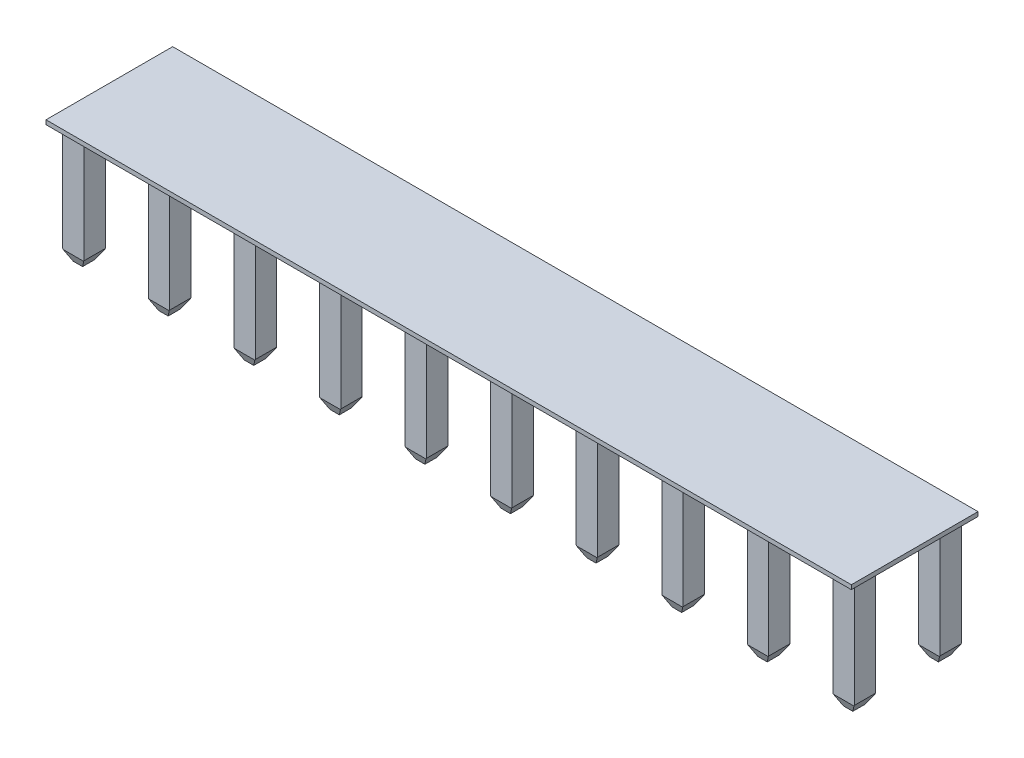
from build123d import *

# Parameters (mm, degrees)
SKETCH1_W            = 23.9014
SKETCH1_H            = 3.7592
BOSS_EXTRUDE1_DEPTH  = 0.127
SKETCH2_W            = 0.635
SKETCH2_H            = 0.635
BOSS_EXTRUDE2_DEPTH  = 3.5306
SKETCH3_W            = 0.635
SKETCH3_H            = 0.635
BOSS_EXTRUDE3_DEPTH  = 3.5306
SKETCH4_W            = 0.635
SKETCH4_H            = 0.635
BOSS_EXTRUDE4_DEPTH  = 3.5306
SKETCH5_W            = 0.635
SKETCH5_H            = 0.635
BOSS_EXTRUDE5_DEPTH  = 3.5306
SKETCH6_W            = 0.635
SKETCH6_H            = 0.635
BOSS_EXTRUDE6_DEPTH  = 3.5306
SKETCH7_W            = 0.635
SKETCH7_H            = 0.635
BOSS_EXTRUDE7_DEPTH  = 3.5306
SKETCH8_W            = 0.635
SKETCH8_H            = 0.635
BOSS_EXTRUDE8_DEPTH  = 3.5306
SKETCH9_W            = 0.635
SKETCH9_H            = 0.635
BOSS_EXTRUDE9_DEPTH  = 3.5306
SKETCH10_W           = 0.635
SKETCH10_H           = 0.635
BOSS_EXTRUDE10_DEPTH = 3.5306
SKETCH11_W           = 0.635
SKETCH11_H           = 0.635
BOSS_EXTRUDE11_DEPTH = 3.5306
SKETCH12_W           = 0.635
SKETCH12_H           = 0.635
BOSS_EXTRUDE12_DEPTH = 3.5306
SKETCH13_W           = 0.635
SKETCH13_H           = 0.635
BOSS_EXTRUDE13_DEPTH = 3.5306
SKETCH14_W           = 0.635
SKETCH14_H           = 0.635
BOSS_EXTRUDE14_DEPTH = 3.5306
SKETCH15_W           = 0.635
SKETCH15_H           = 0.635
BOSS_EXTRUDE15_DEPTH = 3.5306
SKETCH16_W           = 0.635
SKETCH16_H           = 0.635
BOSS_EXTRUDE16_DEPTH = 3.5306
SKETCH17_W           = 0.635
SKETCH17_H           = 0.635
BOSS_EXTRUDE17_DEPTH = 3.5306
SKETCH18_W           = 0.635
SKETCH18_H           = 0.635
BOSS_EXTRUDE18_DEPTH = 3.5306
SKETCH19_W           = 0.635
SKETCH19_H           = 0.635
BOSS_EXTRUDE19_DEPTH = 3.5306
SKETCH20_W           = 0.635
SKETCH20_H           = 0.635
BOSS_EXTRUDE20_DEPTH = 3.5306
SKETCH21_W           = 0.635
SKETCH21_H           = 0.635
BOSS_EXTRUDE21_DEPTH = 3.5306
CHAMFER1_SIZE        = 0.307958634
CHAMFER1_SIZE2       = 0.1778
CHAMFER2_SIZE        = 0.307958634
CHAMFER2_SIZE2       = 0.1778
CHAMFER3_SIZE        = 0.307958634
CHAMFER3_SIZE2       = 0.1778
CHAMFER4_SIZE        = 0.307958634
CHAMFER4_SIZE2       = 0.1778
CHAMFER5_SIZE        = 0.307958634
CHAMFER5_SIZE2       = 0.1778
CHAMFER6_SIZE        = 0.307958634
CHAMFER6_SIZE2       = 0.1778
CHAMFER7_SIZE        = 0.307958634
CHAMFER7_SIZE2       = 0.1778
CHAMFER8_SIZE        = 0.307958634
CHAMFER8_SIZE2       = 0.1778
CHAMFER9_SIZE        = 0.307958634
CHAMFER9_SIZE2       = 0.1778
CHAMFER10_SIZE       = 0.307958634
CHAMFER10_SIZE2      = 0.1778
CHAMFER11_SIZE       = 0.1778
CHAMFER11_SIZE2      = 0.307958634
CHAMFER12_SIZE       = 0.1778
CHAMFER12_SIZE2      = 0.307958634
CHAMFER13_SIZE       = 0.1778
CHAMFER13_SIZE2      = 0.307958634
CHAMFER14_SIZE       = 0.1778
CHAMFER14_SIZE2      = 0.307958634
CHAMFER15_SIZE       = 0.1778
CHAMFER15_SIZE2      = 0.307958634
CHAMFER16_SIZE       = 0.1778
CHAMFER16_SIZE2      = 0.307958634
CHAMFER17_SIZE       = 0.1778
CHAMFER17_SIZE2      = 0.307958634
CHAMFER18_SIZE       = 0.1778
CHAMFER18_SIZE2      = 0.307958634
CHAMFER19_SIZE       = 0.1778
CHAMFER19_SIZE2      = 0.307958634
CHAMFER20_SIZE       = 0.1778
CHAMFER20_SIZE2      = 0.307958634
CHAMFER21_SIZE       = 0.1778
CHAMFER21_SIZE2      = 0.307958634
CHAMFER22_SIZE       = 0.1778
CHAMFER22_SIZE2      = 0.307958634
CHAMFER23_SIZE       = 0.1778
CHAMFER23_SIZE2      = 0.307958634
CHAMFER24_SIZE       = 0.1778
CHAMFER24_SIZE2      = 0.307958634
CHAMFER25_SIZE       = 0.1778
CHAMFER25_SIZE2      = 0.307958634
CHAMFER26_SIZE       = 0.1778
CHAMFER26_SIZE2      = 0.307958634
CHAMFER27_SIZE       = 0.1778
CHAMFER27_SIZE2      = 0.307958634
CHAMFER28_SIZE       = 0.1778
CHAMFER28_SIZE2      = 0.307958634
CHAMFER29_SIZE       = 0.1778
CHAMFER29_SIZE2      = 0.307958634
CHAMFER30_SIZE       = 0.1778
CHAMFER30_SIZE2      = 0.307958634
CHAMFER31_SIZE       = 0.307958634
CHAMFER31_SIZE2      = 0.1778
CHAMFER32_SIZE       = 0.307958634
CHAMFER32_SIZE2      = 0.1778
CHAMFER33_SIZE       = 0.307958634
CHAMFER33_SIZE2      = 0.1778
CHAMFER34_SIZE       = 0.307958634
CHAMFER34_SIZE2      = 0.1778
CHAMFER35_SIZE       = 0.307958634
CHAMFER35_SIZE2      = 0.1778
CHAMFER36_SIZE       = 0.307958634
CHAMFER36_SIZE2      = 0.1778
CHAMFER37_SIZE       = 0.307958634
CHAMFER37_SIZE2      = 0.1778
CHAMFER38_SIZE       = 0.307958634
CHAMFER38_SIZE2      = 0.1778
CHAMFER39_SIZE       = 0.307958634
CHAMFER39_SIZE2      = 0.1778
CHAMFER40_SIZE       = 0.307958634
CHAMFER40_SIZE2      = 0.1778
CHAMFER41_SIZE       = 0.13335
CHAMFER41_SIZE2      = 0.285969998
CHAMFER42_SIZE       = 0.13335
CHAMFER42_SIZE2      = 0.285969998
CHAMFER43_SIZE       = 0.13335
CHAMFER43_SIZE2      = 0.285969998
CHAMFER44_SIZE       = 0.13335
CHAMFER44_SIZE2      = 0.285969998
CHAMFER45_SIZE       = 0.13335
CHAMFER45_SIZE2      = 0.285969998
CHAMFER46_SIZE       = 0.13335
CHAMFER46_SIZE2      = 0.285969998
CHAMFER47_SIZE       = 0.13335
CHAMFER47_SIZE2      = 0.285969998
CHAMFER48_SIZE       = 0.13335
CHAMFER48_SIZE2      = 0.285969998
CHAMFER49_SIZE       = 0.13335
CHAMFER49_SIZE2      = 0.285969998
CHAMFER50_SIZE       = 0.285969998
CHAMFER50_SIZE2      = 0.13335
CHAMFER51_SIZE       = 0.13335
CHAMFER51_SIZE2      = 0.285969998
CHAMFER52_SIZE       = 0.13335
CHAMFER52_SIZE2      = 0.285969998
CHAMFER53_SIZE       = 0.13335
CHAMFER53_SIZE2      = 0.285969998
CHAMFER54_SIZE       = 0.13335
CHAMFER54_SIZE2      = 0.285969998
CHAMFER55_SIZE       = 0.13335
CHAMFER55_SIZE2      = 0.285969998
CHAMFER56_SIZE       = 0.13335
CHAMFER56_SIZE2      = 0.285969998
CHAMFER57_SIZE       = 0.13335
CHAMFER57_SIZE2      = 0.285969998
CHAMFER58_SIZE       = 0.13335
CHAMFER58_SIZE2      = 0.285969998
CHAMFER59_SIZE       = 0.13335
CHAMFER59_SIZE2      = 0.285969998
CHAMFER60_SIZE       = 0.13335
CHAMFER60_SIZE2      = 0.285969998
CHAMFER61_SIZE       = 0.285969998
CHAMFER61_SIZE2      = 0.13335
CHAMFER62_SIZE       = 0.285969998
CHAMFER62_SIZE2      = 0.13335
CHAMFER63_SIZE       = 0.285969998
CHAMFER63_SIZE2      = 0.13335
CHAMFER64_SIZE       = 0.285969998
CHAMFER64_SIZE2      = 0.13335
CHAMFER65_SIZE       = 0.285969998
CHAMFER65_SIZE2      = 0.13335
CHAMFER66_SIZE       = 0.285969998
CHAMFER66_SIZE2      = 0.13335
CHAMFER67_SIZE       = 0.285969998
CHAMFER67_SIZE2      = 0.13335
CHAMFER68_SIZE       = 0.285969998
CHAMFER68_SIZE2      = 0.13335
CHAMFER69_SIZE       = 0.285969998
CHAMFER69_SIZE2      = 0.13335
CHAMFER70_SIZE       = 0.285969998
CHAMFER70_SIZE2      = 0.13335
CHAMFER71_SIZE       = 0.13335
CHAMFER71_SIZE2      = 0.285969998
CHAMFER72_SIZE       = 0.285969998
CHAMFER72_SIZE2      = 0.13335
CHAMFER73_SIZE       = 0.285969998
CHAMFER73_SIZE2      = 0.13335
CHAMFER74_SIZE       = 0.285969998
CHAMFER74_SIZE2      = 0.13335
CHAMFER75_SIZE       = 0.285969998
CHAMFER75_SIZE2      = 0.13335
CHAMFER76_SIZE       = 0.285969998
CHAMFER76_SIZE2      = 0.13335
CHAMFER77_SIZE       = 0.285969998
CHAMFER77_SIZE2      = 0.13335
CHAMFER78_SIZE       = 0.285969998
CHAMFER78_SIZE2      = 0.13335
CHAMFER79_SIZE       = 0.285969998
CHAMFER79_SIZE2      = 0.13335
CHAMFER80_SIZE       = 0.285969998
CHAMFER80_SIZE2      = 0.13335


with BuildPart() as part:
    # Sketch1 → Boss-Extrude1 (new body)
    with BuildSketch(Plane.XZ.offset(-3.5306)):
        Rectangle(SKETCH1_W, SKETCH1_H)
    extrude(amount=-BOSS_EXTRUDE1_DEPTH)

    # Sketch2 → Boss-Extrude2 (add)
    with BuildSketch(Plane.XZ.offset(-3.5306)):
        with Locations((11.43, 1.27)):
            Rectangle(SKETCH2_W, SKETCH2_H)
    extrude(amount=BOSS_EXTRUDE2_DEPTH)

    # Sketch3 → Boss-Extrude3 (add)
    with BuildSketch(Plane.XZ.offset(-3.5306)):
        with Locations((8.89, 1.27)):
            Rectangle(SKETCH3_W, SKETCH3_H)
    extrude(amount=BOSS_EXTRUDE3_DEPTH)

    # Sketch4 → Boss-Extrude4 (add)
    with BuildSketch(Plane.XZ.offset(-3.5306)):
        with Locations((6.35, 1.27)):
            Rectangle(SKETCH4_W, SKETCH4_H)
    extrude(amount=BOSS_EXTRUDE4_DEPTH)

    # Sketch5 → Boss-Extrude5 (add)
    with BuildSketch(Plane.XZ.offset(-3.5306)):
        with Locations((3.81, 1.27)):
            Rectangle(SKETCH5_W, SKETCH5_H)
    extrude(amount=BOSS_EXTRUDE5_DEPTH)

    # Sketch6 → Boss-Extrude6 (add)
    with BuildSketch(Plane.XZ.offset(-3.5306)):
        with Locations((1.27, 1.27)):
            Rectangle(SKETCH6_W, SKETCH6_H)
    extrude(amount=BOSS_EXTRUDE6_DEPTH)

    # Sketch7 → Boss-Extrude7 (add)
    with BuildSketch(Plane.XZ.offset(-3.5306)):
        with Locations((-1.27, 1.27)):
            Rectangle(SKETCH7_W, SKETCH7_H)
    extrude(amount=BOSS_EXTRUDE7_DEPTH)

    # Sketch8 → Boss-Extrude8 (add)
    with BuildSketch(Plane.XZ.offset(-3.5306)):
        with Locations((-3.81, 1.27)):
            Rectangle(SKETCH8_W, SKETCH8_H)
    extrude(amount=BOSS_EXTRUDE8_DEPTH)

    # Sketch9 → Boss-Extrude9 (add)
    with BuildSketch(Plane.XZ.offset(-3.5306)):
        with Locations((-6.35, 1.27)):
            Rectangle(SKETCH9_W, SKETCH9_H)
    extrude(amount=BOSS_EXTRUDE9_DEPTH)

    # Sketch10 → Boss-Extrude10 (add)
    with BuildSketch(Plane.XZ.offset(-3.5306)):
        with Locations((-8.89, 1.27)):
            Rectangle(SKETCH10_W, SKETCH10_H)
    extrude(amount=BOSS_EXTRUDE10_DEPTH)

    # Sketch11 → Boss-Extrude11 (add)
    with BuildSketch(Plane.XZ.offset(-3.5306)):
        with Locations((-11.43, 1.27)):
            Rectangle(SKETCH11_W, SKETCH11_H)
    extrude(amount=BOSS_EXTRUDE11_DEPTH)

    # Sketch12 → Boss-Extrude12 (add)
    with BuildSketch(Plane.XZ.offset(-3.5306)):
        with Locations((11.43, -1.27)):
            Rectangle(SKETCH12_W, SKETCH12_H)
    extrude(amount=BOSS_EXTRUDE12_DEPTH)

    # Sketch13 → Boss-Extrude13 (add)
    with BuildSketch(Plane.XZ.offset(-3.5306)):
        with Locations((8.89, -1.27)):
            Rectangle(SKETCH13_W, SKETCH13_H)
    extrude(amount=BOSS_EXTRUDE13_DEPTH)

    # Sketch14 → Boss-Extrude14 (add)
    with BuildSketch(Plane.XZ.offset(-3.5306)):
        with Locations((6.35, -1.27)):
            Rectangle(SKETCH14_W, SKETCH14_H)
    extrude(amount=BOSS_EXTRUDE14_DEPTH)

    # Sketch15 → Boss-Extrude15 (add)
    with BuildSketch(Plane.XZ.offset(-3.5306)):
        with Locations((3.81, -1.27)):
            Rectangle(SKETCH15_W, SKETCH15_H)
    extrude(amount=BOSS_EXTRUDE15_DEPTH)

    # Sketch16 → Boss-Extrude16 (add)
    with BuildSketch(Plane.XZ.offset(-3.5306)):
        with Locations((1.27, -1.27)):
            Rectangle(SKETCH16_W, SKETCH16_H)
    extrude(amount=BOSS_EXTRUDE16_DEPTH)

    # Sketch17 → Boss-Extrude17 (add)
    with BuildSketch(Plane.XZ.offset(-3.5306)):
        with Locations((-1.27, -1.27)):
            Rectangle(SKETCH17_W, SKETCH17_H)
    extrude(amount=BOSS_EXTRUDE17_DEPTH)

    # Sketch18 → Boss-Extrude18 (add)
    with BuildSketch(Plane.XZ.offset(-3.5306)):
        with Locations((-3.81, -1.27)):
            Rectangle(SKETCH18_W, SKETCH18_H)
    extrude(amount=BOSS_EXTRUDE18_DEPTH)

    # Sketch19 → Boss-Extrude19 (add)
    with BuildSketch(Plane.XZ.offset(-3.5306)):
        with Locations((-6.35, -1.27)):
            Rectangle(SKETCH19_W, SKETCH19_H)
    extrude(amount=BOSS_EXTRUDE19_DEPTH)

    # Sketch20 → Boss-Extrude20 (add)
    with BuildSketch(Plane.XZ.offset(-3.5306)):
        with Locations((-8.89, -1.27)):
            Rectangle(SKETCH20_W, SKETCH20_H)
    extrude(amount=BOSS_EXTRUDE20_DEPTH)

    # Sketch21 → Boss-Extrude21 (add)
    with BuildSketch(Plane.XZ.offset(-3.5306)):
        with Locations((-11.43, -1.27)):
            Rectangle(SKETCH21_W, SKETCH21_H)
    extrude(amount=BOSS_EXTRUDE21_DEPTH)

    # Chamfer1
    chamfer1_edges = [part.edges().sort_by_distance(p)[0] for p in [
        (11.7475, 0, 1.27),
    ]]
    chamfer1_side = [part.faces().sort_by_distance(p)[0] for p in [
        (11.7475, 1.7653, 1.27),
    ]]
    chamfer(chamfer1_edges, length=CHAMFER1_SIZE, length2=CHAMFER1_SIZE2, reference=chamfer1_side[0])

    # Chamfer2
    chamfer2_edges = [part.edges().sort_by_distance(p)[0] for p in [
        (9.2075, 0, 1.27),
    ]]
    chamfer2_side = [part.faces().sort_by_distance(p)[0] for p in [
        (9.2075, 1.7653, 1.27),
    ]]
    chamfer(chamfer2_edges, length=CHAMFER2_SIZE, length2=CHAMFER2_SIZE2, reference=chamfer2_side[0])

    # Chamfer3
    chamfer3_edges = [part.edges().sort_by_distance(p)[0] for p in [
        (6.6675, 0, 1.27),
    ]]
    chamfer3_side = [part.faces().sort_by_distance(p)[0] for p in [
        (6.6675, 1.7653, 1.27),
    ]]
    chamfer(chamfer3_edges, length=CHAMFER3_SIZE, length2=CHAMFER3_SIZE2, reference=chamfer3_side[0])

    # Chamfer4
    chamfer4_edges = [part.edges().sort_by_distance(p)[0] for p in [
        (4.1275, 0, 1.27),
    ]]
    chamfer4_side = [part.faces().sort_by_distance(p)[0] for p in [
        (4.1275, 1.7653, 1.27),
    ]]
    chamfer(chamfer4_edges, length=CHAMFER4_SIZE, length2=CHAMFER4_SIZE2, reference=chamfer4_side[0])

    # Chamfer5
    chamfer5_edges = [part.edges().sort_by_distance(p)[0] for p in [
        (1.5875, 0, 1.27),
    ]]
    chamfer5_side = [part.faces().sort_by_distance(p)[0] for p in [
        (1.5875, 1.7653, 1.27),
    ]]
    chamfer(chamfer5_edges, length=CHAMFER5_SIZE, length2=CHAMFER5_SIZE2, reference=chamfer5_side[0])

    # Chamfer6
    chamfer6_edges = [part.edges().sort_by_distance(p)[0] for p in [
        (-0.9525, 0, 1.27),
    ]]
    chamfer6_side = [part.faces().sort_by_distance(p)[0] for p in [
        (-0.9525, 1.7653, 1.27),
    ]]
    chamfer(chamfer6_edges, length=CHAMFER6_SIZE, length2=CHAMFER6_SIZE2, reference=chamfer6_side[0])

    # Chamfer7
    chamfer7_edges = [part.edges().sort_by_distance(p)[0] for p in [
        (-3.4925, 0, 1.27),
    ]]
    chamfer7_side = [part.faces().sort_by_distance(p)[0] for p in [
        (-3.4925, 1.7653, 1.27),
    ]]
    chamfer(chamfer7_edges, length=CHAMFER7_SIZE, length2=CHAMFER7_SIZE2, reference=chamfer7_side[0])

    # Chamfer8
    chamfer8_edges = [part.edges().sort_by_distance(p)[0] for p in [
        (-6.0325, 0, 1.27),
    ]]
    chamfer8_side = [part.faces().sort_by_distance(p)[0] for p in [
        (-6.0325, 1.7653, 1.27),
    ]]
    chamfer(chamfer8_edges, length=CHAMFER8_SIZE, length2=CHAMFER8_SIZE2, reference=chamfer8_side[0])

    # Chamfer9
    chamfer9_edges = [part.edges().sort_by_distance(p)[0] for p in [
        (-8.5725, 0, 1.27),
    ]]
    chamfer9_side = [part.faces().sort_by_distance(p)[0] for p in [
        (-8.5725, 1.7653, 1.27),
    ]]
    chamfer(chamfer9_edges, length=CHAMFER9_SIZE, length2=CHAMFER9_SIZE2, reference=chamfer9_side[0])

    # Chamfer10
    chamfer10_edges = [part.edges().sort_by_distance(p)[0] for p in [
        (-11.1125, 0, 1.27),
    ]]
    chamfer10_side = [part.faces().sort_by_distance(p)[0] for p in [
        (-11.1125, 1.7653, 1.27),
    ]]
    chamfer(chamfer10_edges, length=CHAMFER10_SIZE, length2=CHAMFER10_SIZE2, reference=chamfer10_side[0])

    # Chamfer11
    chamfer11_edges = [part.edges().sort_by_distance(p)[0] for p in [
        (11.1125, 0, 1.27),
    ]]
    chamfer11_side = [part.faces().sort_by_distance(p)[0] for p in [
        (11.3411, 0, 1.27),
    ]]
    chamfer(chamfer11_edges, length=CHAMFER11_SIZE, length2=CHAMFER11_SIZE2, reference=chamfer11_side[0])

    # Chamfer12
    chamfer12_edges = [part.edges().sort_by_distance(p)[0] for p in [
        (8.5725, 0, 1.27),
    ]]
    chamfer12_side = [part.faces().sort_by_distance(p)[0] for p in [
        (8.8011, 0, 1.27),
    ]]
    chamfer(chamfer12_edges, length=CHAMFER12_SIZE, length2=CHAMFER12_SIZE2, reference=chamfer12_side[0])

    # Chamfer13
    chamfer13_edges = [part.edges().sort_by_distance(p)[0] for p in [
        (6.0325, 0, 1.27),
    ]]
    chamfer13_side = [part.faces().sort_by_distance(p)[0] for p in [
        (6.2611, 0, 1.27),
    ]]
    chamfer(chamfer13_edges, length=CHAMFER13_SIZE, length2=CHAMFER13_SIZE2, reference=chamfer13_side[0])

    # Chamfer14
    chamfer14_edges = [part.edges().sort_by_distance(p)[0] for p in [
        (3.4925, 0, 1.27),
    ]]
    chamfer14_side = [part.faces().sort_by_distance(p)[0] for p in [
        (3.7211, 0, 1.27),
    ]]
    chamfer(chamfer14_edges, length=CHAMFER14_SIZE, length2=CHAMFER14_SIZE2, reference=chamfer14_side[0])

    # Chamfer15
    chamfer15_edges = [part.edges().sort_by_distance(p)[0] for p in [
        (0.9525, 0, 1.27),
    ]]
    chamfer15_side = [part.faces().sort_by_distance(p)[0] for p in [
        (1.1811, 0, 1.27),
    ]]
    chamfer(chamfer15_edges, length=CHAMFER15_SIZE, length2=CHAMFER15_SIZE2, reference=chamfer15_side[0])

    # Chamfer16
    chamfer16_edges = [part.edges().sort_by_distance(p)[0] for p in [
        (-1.5875, 0, 1.27),
    ]]
    chamfer16_side = [part.faces().sort_by_distance(p)[0] for p in [
        (-1.3589, 0, 1.27),
    ]]
    chamfer(chamfer16_edges, length=CHAMFER16_SIZE, length2=CHAMFER16_SIZE2, reference=chamfer16_side[0])

    # Chamfer17
    chamfer17_edges = [part.edges().sort_by_distance(p)[0] for p in [
        (-4.1275, 0, 1.27),
    ]]
    chamfer17_side = [part.faces().sort_by_distance(p)[0] for p in [
        (-3.8989, 0, 1.27),
    ]]
    chamfer(chamfer17_edges, length=CHAMFER17_SIZE, length2=CHAMFER17_SIZE2, reference=chamfer17_side[0])

    # Chamfer18
    chamfer18_edges = [part.edges().sort_by_distance(p)[0] for p in [
        (-6.6675, 0, 1.27),
    ]]
    chamfer18_side = [part.faces().sort_by_distance(p)[0] for p in [
        (-6.4389, 0, 1.27),
    ]]
    chamfer(chamfer18_edges, length=CHAMFER18_SIZE, length2=CHAMFER18_SIZE2, reference=chamfer18_side[0])

    # Chamfer19
    chamfer19_edges = [part.edges().sort_by_distance(p)[0] for p in [
        (-9.2075, 0, 1.27),
    ]]
    chamfer19_side = [part.faces().sort_by_distance(p)[0] for p in [
        (-8.9789, 0, 1.27),
    ]]
    chamfer(chamfer19_edges, length=CHAMFER19_SIZE, length2=CHAMFER19_SIZE2, reference=chamfer19_side[0])

    # Chamfer20
    chamfer20_edges = [part.edges().sort_by_distance(p)[0] for p in [
        (-11.7475, 0, 1.27),
    ]]
    chamfer20_side = [part.faces().sort_by_distance(p)[0] for p in [
        (-11.5189, 0, 1.27),
    ]]
    chamfer(chamfer20_edges, length=CHAMFER20_SIZE, length2=CHAMFER20_SIZE2, reference=chamfer20_side[0])

    # Chamfer21
    chamfer21_edges = [part.edges().sort_by_distance(p)[0] for p in [
        (11.7475, 0, -1.27),
    ]]
    chamfer21_side = [part.faces().sort_by_distance(p)[0] for p in [
        (11.43, 0, -1.27),
    ]]
    chamfer(chamfer21_edges, length=CHAMFER21_SIZE, length2=CHAMFER21_SIZE2, reference=chamfer21_side[0])

    # Chamfer22
    chamfer22_edges = [part.edges().sort_by_distance(p)[0] for p in [
        (9.2075, 0, -1.27),
    ]]
    chamfer22_side = [part.faces().sort_by_distance(p)[0] for p in [
        (8.89, 0, -1.27),
    ]]
    chamfer(chamfer22_edges, length=CHAMFER22_SIZE, length2=CHAMFER22_SIZE2, reference=chamfer22_side[0])

    # Chamfer23
    chamfer23_edges = [part.edges().sort_by_distance(p)[0] for p in [
        (6.6675, 0, -1.27),
    ]]
    chamfer23_side = [part.faces().sort_by_distance(p)[0] for p in [
        (6.35, 0, -1.27),
    ]]
    chamfer(chamfer23_edges, length=CHAMFER23_SIZE, length2=CHAMFER23_SIZE2, reference=chamfer23_side[0])

    # Chamfer24
    chamfer24_edges = [part.edges().sort_by_distance(p)[0] for p in [
        (4.1275, 0, -1.27),
    ]]
    chamfer24_side = [part.faces().sort_by_distance(p)[0] for p in [
        (3.81, 0, -1.27),
    ]]
    chamfer(chamfer24_edges, length=CHAMFER24_SIZE, length2=CHAMFER24_SIZE2, reference=chamfer24_side[0])

    # Chamfer25
    chamfer25_edges = [part.edges().sort_by_distance(p)[0] for p in [
        (1.5875, 0, -1.27),
    ]]
    chamfer25_side = [part.faces().sort_by_distance(p)[0] for p in [
        (1.27, 0, -1.27),
    ]]
    chamfer(chamfer25_edges, length=CHAMFER25_SIZE, length2=CHAMFER25_SIZE2, reference=chamfer25_side[0])

    # Chamfer26
    chamfer26_edges = [part.edges().sort_by_distance(p)[0] for p in [
        (-0.9525, 0, -1.27),
    ]]
    chamfer26_side = [part.faces().sort_by_distance(p)[0] for p in [
        (-1.27, 0, -1.27),
    ]]
    chamfer(chamfer26_edges, length=CHAMFER26_SIZE, length2=CHAMFER26_SIZE2, reference=chamfer26_side[0])

    # Chamfer27
    chamfer27_edges = [part.edges().sort_by_distance(p)[0] for p in [
        (-3.4925, 0, -1.27),
    ]]
    chamfer27_side = [part.faces().sort_by_distance(p)[0] for p in [
        (-3.81, 0, -1.27),
    ]]
    chamfer(chamfer27_edges, length=CHAMFER27_SIZE, length2=CHAMFER27_SIZE2, reference=chamfer27_side[0])

    # Chamfer28
    chamfer28_edges = [part.edges().sort_by_distance(p)[0] for p in [
        (-6.0325, 0, -1.27),
    ]]
    chamfer28_side = [part.faces().sort_by_distance(p)[0] for p in [
        (-6.35, 0, -1.27),
    ]]
    chamfer(chamfer28_edges, length=CHAMFER28_SIZE, length2=CHAMFER28_SIZE2, reference=chamfer28_side[0])

    # Chamfer29
    chamfer29_edges = [part.edges().sort_by_distance(p)[0] for p in [
        (-8.5725, 0, -1.27),
    ]]
    chamfer29_side = [part.faces().sort_by_distance(p)[0] for p in [
        (-8.89, 0, -1.27),
    ]]
    chamfer(chamfer29_edges, length=CHAMFER29_SIZE, length2=CHAMFER29_SIZE2, reference=chamfer29_side[0])

    # Chamfer30
    chamfer30_edges = [part.edges().sort_by_distance(p)[0] for p in [
        (-11.1125, 0, -1.27),
    ]]
    chamfer30_side = [part.faces().sort_by_distance(p)[0] for p in [
        (-11.43, 0, -1.27),
    ]]
    chamfer(chamfer30_edges, length=CHAMFER30_SIZE, length2=CHAMFER30_SIZE2, reference=chamfer30_side[0])

    # Chamfer31
    chamfer31_edges = [part.edges().sort_by_distance(p)[0] for p in [
        (11.1125, 0, -1.27),
    ]]
    chamfer31_side = [part.faces().sort_by_distance(p)[0] for p in [
        (11.1125, 1.7653, -1.27),
    ]]
    chamfer(chamfer31_edges, length=CHAMFER31_SIZE, length2=CHAMFER31_SIZE2, reference=chamfer31_side[0])

    # Chamfer32
    chamfer32_edges = [part.edges().sort_by_distance(p)[0] for p in [
        (8.5725, 0, -1.27),
    ]]
    chamfer32_side = [part.faces().sort_by_distance(p)[0] for p in [
        (8.5725, 1.7653, -1.27),
    ]]
    chamfer(chamfer32_edges, length=CHAMFER32_SIZE, length2=CHAMFER32_SIZE2, reference=chamfer32_side[0])

    # Chamfer33
    chamfer33_edges = [part.edges().sort_by_distance(p)[0] for p in [
        (6.0325, 0, -1.27),
    ]]
    chamfer33_side = [part.faces().sort_by_distance(p)[0] for p in [
        (6.0325, 1.7653, -1.27),
    ]]
    chamfer(chamfer33_edges, length=CHAMFER33_SIZE, length2=CHAMFER33_SIZE2, reference=chamfer33_side[0])

    # Chamfer34
    chamfer34_edges = [part.edges().sort_by_distance(p)[0] for p in [
        (3.4925, 0, -1.27),
    ]]
    chamfer34_side = [part.faces().sort_by_distance(p)[0] for p in [
        (3.4925, 1.7653, -1.27),
    ]]
    chamfer(chamfer34_edges, length=CHAMFER34_SIZE, length2=CHAMFER34_SIZE2, reference=chamfer34_side[0])

    # Chamfer35
    chamfer35_edges = [part.edges().sort_by_distance(p)[0] for p in [
        (0.9525, 0, -1.27),
    ]]
    chamfer35_side = [part.faces().sort_by_distance(p)[0] for p in [
        (0.9525, 1.7653, -1.27),
    ]]
    chamfer(chamfer35_edges, length=CHAMFER35_SIZE, length2=CHAMFER35_SIZE2, reference=chamfer35_side[0])

    # Chamfer36
    chamfer36_edges = [part.edges().sort_by_distance(p)[0] for p in [
        (-1.5875, 0, -1.27),
    ]]
    chamfer36_side = [part.faces().sort_by_distance(p)[0] for p in [
        (-1.5875, 1.7653, -1.27),
    ]]
    chamfer(chamfer36_edges, length=CHAMFER36_SIZE, length2=CHAMFER36_SIZE2, reference=chamfer36_side[0])

    # Chamfer37
    chamfer37_edges = [part.edges().sort_by_distance(p)[0] for p in [
        (-4.1275, 0, -1.27),
    ]]
    chamfer37_side = [part.faces().sort_by_distance(p)[0] for p in [
        (-4.1275, 1.7653, -1.27),
    ]]
    chamfer(chamfer37_edges, length=CHAMFER37_SIZE, length2=CHAMFER37_SIZE2, reference=chamfer37_side[0])

    # Chamfer38
    chamfer38_edges = [part.edges().sort_by_distance(p)[0] for p in [
        (-6.6675, 0, -1.27),
    ]]
    chamfer38_side = [part.faces().sort_by_distance(p)[0] for p in [
        (-6.6675, 1.7653, -1.27),
    ]]
    chamfer(chamfer38_edges, length=CHAMFER38_SIZE, length2=CHAMFER38_SIZE2, reference=chamfer38_side[0])

    # Chamfer39
    chamfer39_edges = [part.edges().sort_by_distance(p)[0] for p in [
        (-9.2075, 0, -1.27),
    ]]
    chamfer39_side = [part.faces().sort_by_distance(p)[0] for p in [
        (-9.2075, 1.7653, -1.27),
    ]]
    chamfer(chamfer39_edges, length=CHAMFER39_SIZE, length2=CHAMFER39_SIZE2, reference=chamfer39_side[0])

    # Chamfer40
    chamfer40_edges = [part.edges().sort_by_distance(p)[0] for p in [
        (-11.7475, 0, -1.27),
    ]]
    chamfer40_side = [part.faces().sort_by_distance(p)[0] for p in [
        (-11.7475, 1.7653, -1.27),
    ]]
    chamfer(chamfer40_edges, length=CHAMFER40_SIZE, length2=CHAMFER40_SIZE2, reference=chamfer40_side[0])

    # Chamfer41
    chamfer41_edges = [part.edges().sort_by_distance(p)[0] for p in [
        (11.43, 0, -0.9525),
    ]]
    chamfer41_side = [part.faces().sort_by_distance(p)[0] for p in [
        (11.43, 0, -1.27),
    ]]
    chamfer(chamfer41_edges, length=CHAMFER41_SIZE, length2=CHAMFER41_SIZE2, reference=chamfer41_side[0])

    # Chamfer42
    chamfer42_edges = [part.edges().sort_by_distance(p)[0] for p in [
        (8.89, 0, -0.9525),
    ]]
    chamfer42_side = [part.faces().sort_by_distance(p)[0] for p in [
        (8.89, 0, -1.27),
    ]]
    chamfer(chamfer42_edges, length=CHAMFER42_SIZE, length2=CHAMFER42_SIZE2, reference=chamfer42_side[0])

    # Chamfer43
    chamfer43_edges = [part.edges().sort_by_distance(p)[0] for p in [
        (6.35, 0, -0.9525),
    ]]
    chamfer43_side = [part.faces().sort_by_distance(p)[0] for p in [
        (6.35, 0, -1.27),
    ]]
    chamfer(chamfer43_edges, length=CHAMFER43_SIZE, length2=CHAMFER43_SIZE2, reference=chamfer43_side[0])

    # Chamfer44
    chamfer44_edges = [part.edges().sort_by_distance(p)[0] for p in [
        (3.81, 0, -0.9525),
    ]]
    chamfer44_side = [part.faces().sort_by_distance(p)[0] for p in [
        (3.81, 0, -1.27),
    ]]
    chamfer(chamfer44_edges, length=CHAMFER44_SIZE, length2=CHAMFER44_SIZE2, reference=chamfer44_side[0])

    # Chamfer45
    chamfer45_edges = [part.edges().sort_by_distance(p)[0] for p in [
        (1.27, 0, -0.9525),
    ]]
    chamfer45_side = [part.faces().sort_by_distance(p)[0] for p in [
        (1.27, 0, -1.27),
    ]]
    chamfer(chamfer45_edges, length=CHAMFER45_SIZE, length2=CHAMFER45_SIZE2, reference=chamfer45_side[0])

    # Chamfer46
    chamfer46_edges = [part.edges().sort_by_distance(p)[0] for p in [
        (-1.27, 0, -0.9525),
    ]]
    chamfer46_side = [part.faces().sort_by_distance(p)[0] for p in [
        (-1.27, 0, -1.27),
    ]]
    chamfer(chamfer46_edges, length=CHAMFER46_SIZE, length2=CHAMFER46_SIZE2, reference=chamfer46_side[0])

    # Chamfer47
    chamfer47_edges = [part.edges().sort_by_distance(p)[0] for p in [
        (-3.81, 0, -0.9525),
    ]]
    chamfer47_side = [part.faces().sort_by_distance(p)[0] for p in [
        (-3.81, 0, -1.27),
    ]]
    chamfer(chamfer47_edges, length=CHAMFER47_SIZE, length2=CHAMFER47_SIZE2, reference=chamfer47_side[0])

    # Chamfer48
    chamfer48_edges = [part.edges().sort_by_distance(p)[0] for p in [
        (-6.35, 0, -0.9525),
    ]]
    chamfer48_side = [part.faces().sort_by_distance(p)[0] for p in [
        (-6.35, 0, -1.27),
    ]]
    chamfer(chamfer48_edges, length=CHAMFER48_SIZE, length2=CHAMFER48_SIZE2, reference=chamfer48_side[0])

    # Chamfer49
    chamfer49_edges = [part.edges().sort_by_distance(p)[0] for p in [
        (-8.89, 0, -0.9525),
    ]]
    chamfer49_side = [part.faces().sort_by_distance(p)[0] for p in [
        (-8.89, 0, -1.27),
    ]]
    chamfer(chamfer49_edges, length=CHAMFER49_SIZE, length2=CHAMFER49_SIZE2, reference=chamfer49_side[0])

    # Chamfer50
    chamfer50_edges = [part.edges().sort_by_distance(p)[0] for p in [
        (-11.43, 0, -0.9525),
    ]]
    chamfer50_side = [part.faces().sort_by_distance(p)[0] for p in [
        (-11.43, 1.806923683, -0.9525),
    ]]
    chamfer(chamfer50_edges, length=CHAMFER50_SIZE, length2=CHAMFER50_SIZE2, reference=chamfer50_side[0])

    # Chamfer51
    chamfer51_edges = [part.edges().sort_by_distance(p)[0] for p in [
        (-11.43, 0, -1.5875),
    ]]
    chamfer51_side = [part.faces().sort_by_distance(p)[0] for p in [
        (-11.43, 0, -1.336675),
    ]]
    chamfer(chamfer51_edges, length=CHAMFER51_SIZE, length2=CHAMFER51_SIZE2, reference=chamfer51_side[0])

    # Chamfer52
    chamfer52_edges = [part.edges().sort_by_distance(p)[0] for p in [
        (11.43, 0, 1.5875),
    ]]
    chamfer52_side = [part.faces().sort_by_distance(p)[0] for p in [
        (11.43, 0, 1.27),
    ]]
    chamfer(chamfer52_edges, length=CHAMFER52_SIZE, length2=CHAMFER52_SIZE2, reference=chamfer52_side[0])

    # Chamfer53
    chamfer53_edges = [part.edges().sort_by_distance(p)[0] for p in [
        (8.89, 0, 1.5875),
    ]]
    chamfer53_side = [part.faces().sort_by_distance(p)[0] for p in [
        (8.89, 0, 1.27),
    ]]
    chamfer(chamfer53_edges, length=CHAMFER53_SIZE, length2=CHAMFER53_SIZE2, reference=chamfer53_side[0])

    # Chamfer54
    chamfer54_edges = [part.edges().sort_by_distance(p)[0] for p in [
        (6.35, 0, 1.5875),
    ]]
    chamfer54_side = [part.faces().sort_by_distance(p)[0] for p in [
        (6.35, 0, 1.27),
    ]]
    chamfer(chamfer54_edges, length=CHAMFER54_SIZE, length2=CHAMFER54_SIZE2, reference=chamfer54_side[0])

    # Chamfer55
    chamfer55_edges = [part.edges().sort_by_distance(p)[0] for p in [
        (3.81, 0, 1.5875),
    ]]
    chamfer55_side = [part.faces().sort_by_distance(p)[0] for p in [
        (3.81, 0, 1.27),
    ]]
    chamfer(chamfer55_edges, length=CHAMFER55_SIZE, length2=CHAMFER55_SIZE2, reference=chamfer55_side[0])

    # Chamfer56
    chamfer56_edges = [part.edges().sort_by_distance(p)[0] for p in [
        (1.27, 0, 1.5875),
    ]]
    chamfer56_side = [part.faces().sort_by_distance(p)[0] for p in [
        (1.27, 0, 1.27),
    ]]
    chamfer(chamfer56_edges, length=CHAMFER56_SIZE, length2=CHAMFER56_SIZE2, reference=chamfer56_side[0])

    # Chamfer57
    chamfer57_edges = [part.edges().sort_by_distance(p)[0] for p in [
        (-1.27, 0, 1.5875),
    ]]
    chamfer57_side = [part.faces().sort_by_distance(p)[0] for p in [
        (-1.27, 0, 1.27),
    ]]
    chamfer(chamfer57_edges, length=CHAMFER57_SIZE, length2=CHAMFER57_SIZE2, reference=chamfer57_side[0])

    # Chamfer58
    chamfer58_edges = [part.edges().sort_by_distance(p)[0] for p in [
        (-3.81, 0, 1.5875),
    ]]
    chamfer58_side = [part.faces().sort_by_distance(p)[0] for p in [
        (-3.81, 0, 1.27),
    ]]
    chamfer(chamfer58_edges, length=CHAMFER58_SIZE, length2=CHAMFER58_SIZE2, reference=chamfer58_side[0])

    # Chamfer59
    chamfer59_edges = [part.edges().sort_by_distance(p)[0] for p in [
        (-6.35, 0, 1.5875),
    ]]
    chamfer59_side = [part.faces().sort_by_distance(p)[0] for p in [
        (-6.35, 0, 1.27),
    ]]
    chamfer(chamfer59_edges, length=CHAMFER59_SIZE, length2=CHAMFER59_SIZE2, reference=chamfer59_side[0])

    # Chamfer60
    chamfer60_edges = [part.edges().sort_by_distance(p)[0] for p in [
        (-8.89, 0, 1.5875),
    ]]
    chamfer60_side = [part.faces().sort_by_distance(p)[0] for p in [
        (-8.89, 0, 1.27),
    ]]
    chamfer(chamfer60_edges, length=CHAMFER60_SIZE, length2=CHAMFER60_SIZE2, reference=chamfer60_side[0])

    # Chamfer61
    chamfer61_edges = [part.edges().sort_by_distance(p)[0] for p in [
        (-11.43, 0, 1.5875),
    ]]
    chamfer61_side = [part.faces().sort_by_distance(p)[0] for p in [
        (-11.43, 1.806923683, 1.5875),
    ]]
    chamfer(chamfer61_edges, length=CHAMFER61_SIZE, length2=CHAMFER61_SIZE2, reference=chamfer61_side[0])

    # Chamfer62
    chamfer62_edges = [part.edges().sort_by_distance(p)[0] for p in [
        (11.43, 0, 0.9525),
    ]]
    chamfer62_side = [part.faces().sort_by_distance(p)[0] for p in [
        (11.43, 1.806923683, 0.9525),
    ]]
    chamfer(chamfer62_edges, length=CHAMFER62_SIZE, length2=CHAMFER62_SIZE2, reference=chamfer62_side[0])

    # Chamfer63
    chamfer63_edges = [part.edges().sort_by_distance(p)[0] for p in [
        (8.89, 0, 0.9525),
    ]]
    chamfer63_side = [part.faces().sort_by_distance(p)[0] for p in [
        (8.89, 1.806923683, 0.9525),
    ]]
    chamfer(chamfer63_edges, length=CHAMFER63_SIZE, length2=CHAMFER63_SIZE2, reference=chamfer63_side[0])

    # Chamfer64
    chamfer64_edges = [part.edges().sort_by_distance(p)[0] for p in [
        (6.35, 0, 0.9525),
    ]]
    chamfer64_side = [part.faces().sort_by_distance(p)[0] for p in [
        (6.35, 1.806923683, 0.9525),
    ]]
    chamfer(chamfer64_edges, length=CHAMFER64_SIZE, length2=CHAMFER64_SIZE2, reference=chamfer64_side[0])

    # Chamfer65
    chamfer65_edges = [part.edges().sort_by_distance(p)[0] for p in [
        (3.81, 0, 0.9525),
    ]]
    chamfer65_side = [part.faces().sort_by_distance(p)[0] for p in [
        (3.81, 1.806923683, 0.9525),
    ]]
    chamfer(chamfer65_edges, length=CHAMFER65_SIZE, length2=CHAMFER65_SIZE2, reference=chamfer65_side[0])

    # Chamfer66
    chamfer66_edges = [part.edges().sort_by_distance(p)[0] for p in [
        (1.27, 0, 0.9525),
    ]]
    chamfer66_side = [part.faces().sort_by_distance(p)[0] for p in [
        (1.27, 1.806923683, 0.9525),
    ]]
    chamfer(chamfer66_edges, length=CHAMFER66_SIZE, length2=CHAMFER66_SIZE2, reference=chamfer66_side[0])

    # Chamfer67
    chamfer67_edges = [part.edges().sort_by_distance(p)[0] for p in [
        (-1.27, 0, 0.9525),
    ]]
    chamfer67_side = [part.faces().sort_by_distance(p)[0] for p in [
        (-1.27, 1.806923683, 0.9525),
    ]]
    chamfer(chamfer67_edges, length=CHAMFER67_SIZE, length2=CHAMFER67_SIZE2, reference=chamfer67_side[0])

    # Chamfer68
    chamfer68_edges = [part.edges().sort_by_distance(p)[0] for p in [
        (-3.81, 0, 0.9525),
    ]]
    chamfer68_side = [part.faces().sort_by_distance(p)[0] for p in [
        (-3.81, 1.806923683, 0.9525),
    ]]
    chamfer(chamfer68_edges, length=CHAMFER68_SIZE, length2=CHAMFER68_SIZE2, reference=chamfer68_side[0])

    # Chamfer69
    chamfer69_edges = [part.edges().sort_by_distance(p)[0] for p in [
        (-6.35, 0, 0.9525),
    ]]
    chamfer69_side = [part.faces().sort_by_distance(p)[0] for p in [
        (-6.35, 1.806923683, 0.9525),
    ]]
    chamfer(chamfer69_edges, length=CHAMFER69_SIZE, length2=CHAMFER69_SIZE2, reference=chamfer69_side[0])

    # Chamfer70
    chamfer70_edges = [part.edges().sort_by_distance(p)[0] for p in [
        (-8.89, 0, 0.9525),
    ]]
    chamfer70_side = [part.faces().sort_by_distance(p)[0] for p in [
        (-8.89, 1.806923683, 0.9525),
    ]]
    chamfer(chamfer70_edges, length=CHAMFER70_SIZE, length2=CHAMFER70_SIZE2, reference=chamfer70_side[0])

    # Chamfer71
    chamfer71_edges = [part.edges().sort_by_distance(p)[0] for p in [
        (-11.43, 0, 0.9525),
    ]]
    chamfer71_side = [part.faces().sort_by_distance(p)[0] for p in [
        (-11.43, 0, 1.203325),
    ]]
    chamfer(chamfer71_edges, length=CHAMFER71_SIZE, length2=CHAMFER71_SIZE2, reference=chamfer71_side[0])

    # Chamfer72
    chamfer72_edges = [part.edges().sort_by_distance(p)[0] for p in [
        (11.43, 0, -1.5875),
    ]]
    chamfer72_side = [part.faces().sort_by_distance(p)[0] for p in [
        (11.43, 1.806923683, -1.5875),
    ]]
    chamfer(chamfer72_edges, length=CHAMFER72_SIZE, length2=CHAMFER72_SIZE2, reference=chamfer72_side[0])

    # Chamfer73
    chamfer73_edges = [part.edges().sort_by_distance(p)[0] for p in [
        (8.89, 0, -1.5875),
    ]]
    chamfer73_side = [part.faces().sort_by_distance(p)[0] for p in [
        (8.89, 1.806923683, -1.5875),
    ]]
    chamfer(chamfer73_edges, length=CHAMFER73_SIZE, length2=CHAMFER73_SIZE2, reference=chamfer73_side[0])

    # Chamfer74
    chamfer74_edges = [part.edges().sort_by_distance(p)[0] for p in [
        (6.35, 0, -1.5875),
    ]]
    chamfer74_side = [part.faces().sort_by_distance(p)[0] for p in [
        (6.35, 1.806923683, -1.5875),
    ]]
    chamfer(chamfer74_edges, length=CHAMFER74_SIZE, length2=CHAMFER74_SIZE2, reference=chamfer74_side[0])

    # Chamfer75
    chamfer75_edges = [part.edges().sort_by_distance(p)[0] for p in [
        (3.81, 0, -1.5875),
    ]]
    chamfer75_side = [part.faces().sort_by_distance(p)[0] for p in [
        (3.81, 1.806923683, -1.5875),
    ]]
    chamfer(chamfer75_edges, length=CHAMFER75_SIZE, length2=CHAMFER75_SIZE2, reference=chamfer75_side[0])

    # Chamfer76
    chamfer76_edges = [part.edges().sort_by_distance(p)[0] for p in [
        (1.27, 0, -1.5875),
    ]]
    chamfer76_side = [part.faces().sort_by_distance(p)[0] for p in [
        (1.27, 1.806923683, -1.5875),
    ]]
    chamfer(chamfer76_edges, length=CHAMFER76_SIZE, length2=CHAMFER76_SIZE2, reference=chamfer76_side[0])

    # Chamfer77
    chamfer77_edges = [part.edges().sort_by_distance(p)[0] for p in [
        (-1.27, 0, -1.5875),
    ]]
    chamfer77_side = [part.faces().sort_by_distance(p)[0] for p in [
        (-1.27, 1.806923683, -1.5875),
    ]]
    chamfer(chamfer77_edges, length=CHAMFER77_SIZE, length2=CHAMFER77_SIZE2, reference=chamfer77_side[0])

    # Chamfer78
    chamfer78_edges = [part.edges().sort_by_distance(p)[0] for p in [
        (-3.81, 0, -1.5875),
    ]]
    chamfer78_side = [part.faces().sort_by_distance(p)[0] for p in [
        (-3.81, 1.806923683, -1.5875),
    ]]
    chamfer(chamfer78_edges, length=CHAMFER78_SIZE, length2=CHAMFER78_SIZE2, reference=chamfer78_side[0])

    # Chamfer79
    chamfer79_edges = [part.edges().sort_by_distance(p)[0] for p in [
        (-6.35, 0, -1.5875),
    ]]
    chamfer79_side = [part.faces().sort_by_distance(p)[0] for p in [
        (-6.35, 1.806923683, -1.5875),
    ]]
    chamfer(chamfer79_edges, length=CHAMFER79_SIZE, length2=CHAMFER79_SIZE2, reference=chamfer79_side[0])

    # Chamfer80
    chamfer80_edges = [part.edges().sort_by_distance(p)[0] for p in [
        (-8.89, 0, -1.5875),
    ]]
    chamfer80_side = [part.faces().sort_by_distance(p)[0] for p in [
        (-8.89, 1.806923683, -1.5875),
    ]]
    chamfer(chamfer80_edges, length=CHAMFER80_SIZE, length2=CHAMFER80_SIZE2, reference=chamfer80_side[0])


solid = part.part
